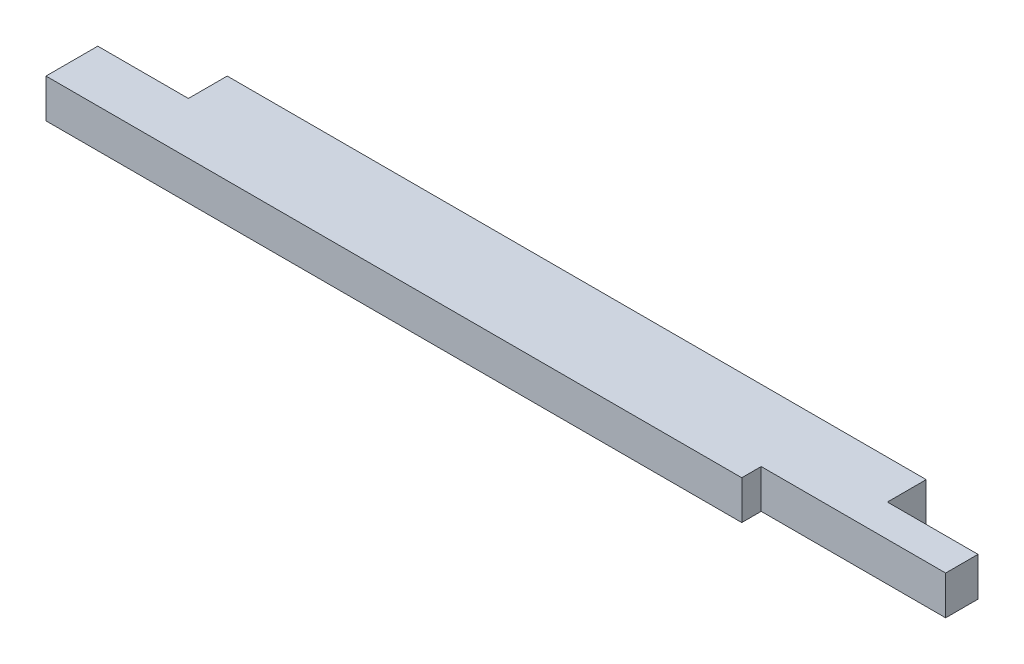
from build123d import *

# Parameters (mm, degrees)
SKETCH1_W           = 863.6
SKETCH1_H           = 88.9
BOSS_EXTRUDE1_DEPTH = 38.1
SKETCH3_W           = 88.9
SKETCH3_H           = 38.1
CUT_EXTRUDE1_DEPTH  = 39.1
SKETCH4_W           = 180.975
SKETCH4_H           = 19.05
CUT_EXTRUDE2_DEPTH  = 39.1


with BuildPart() as part:
    # Sketch1 → Boss-Extrude1 (new body)
    with BuildSketch(Plane(origin=(0, 0, 0), x_dir=(1, 0, 0), z_dir=(0, 1, 0))):
        with Locations((431.8, 44.45)):
            Rectangle(SKETCH1_W, SKETCH1_H)
    extrude(amount=BOSS_EXTRUDE1_DEPTH)

    # Sketch3 → Cut-Extrude1 (cut, through all)
    with BuildSketch(Plane(origin=(0, 38.1, 0), x_dir=(1, 0, 0), z_dir=(0, 1, 0))):
        with Locations((44.45, 69.85)):
            Rectangle(SKETCH3_W, SKETCH3_H)
        with Locations((819.15, 69.85)):
            Rectangle(SKETCH3_W, SKETCH3_H)
    extrude(amount=-CUT_EXTRUDE1_DEPTH, mode=Mode.SUBTRACT)

    # Sketch4 → Cut-Extrude2 (cut, through all)
    with BuildSketch(Plane(origin=(0, 38.1, 0), x_dir=(1, 0, 0), z_dir=(0, 1, 0))):
        with Locations((773.1125, 9.525)):
            Rectangle(SKETCH4_W, SKETCH4_H)
    extrude(amount=-CUT_EXTRUDE2_DEPTH, mode=Mode.SUBTRACT)


solid = part.part
